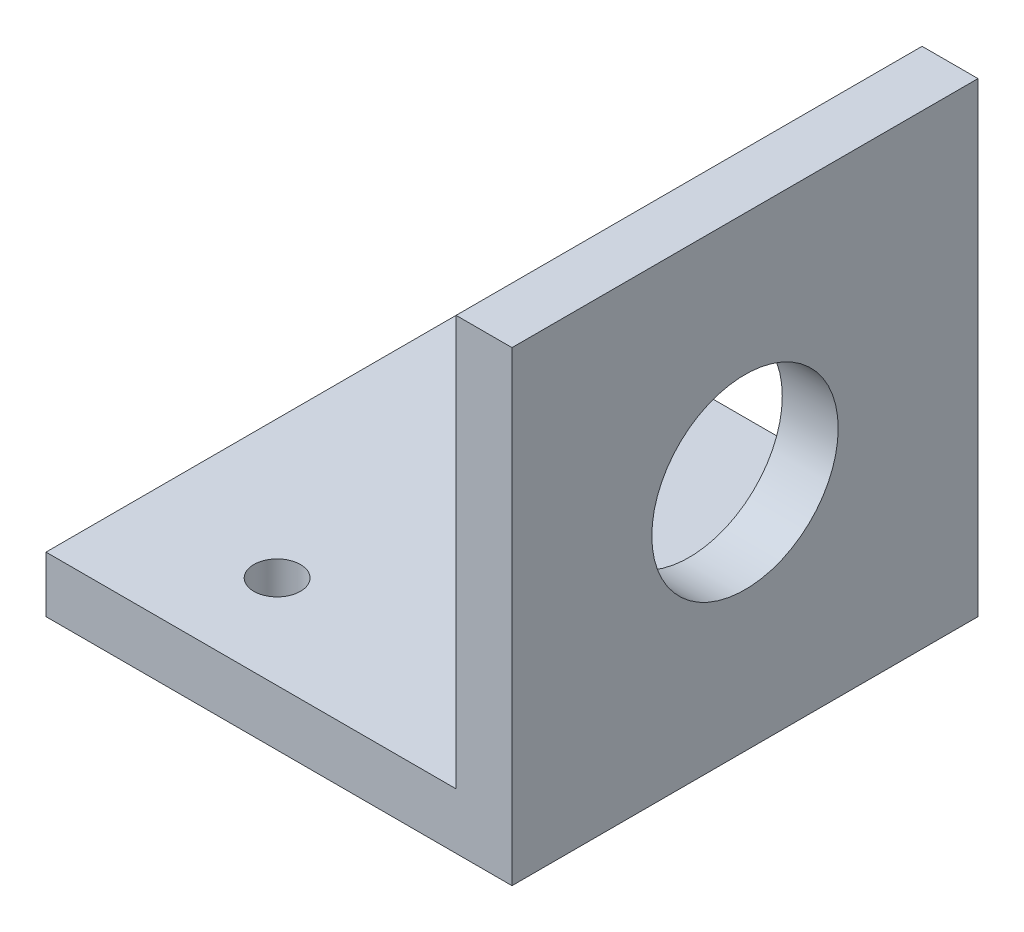
from build123d import *

# Parameters (mm, degrees)
SKETCH_1_W          = 50
SKETCH_1_H          = 50
EXTRUDE_1_DEPTH     = 6
SKETCH_2_W          = 6
SKETCH_2_H          = 50
EXTRUDE_2_DEPTH     = 44
SKETCH_3_R          = 10
CUT_EXTRUDE_1_DEPTH = 44
SKETCH_4_R          = 2.5
CUT_EXTRUDE_2_DEPTH = 44


with BuildPart() as part:
    # ｽｹｯﾁ1 → ﾎﾞｽ - 押し出し1 (new body)
    with BuildSketch(Plane(origin=(0, 0, 0), x_dir=(1, 0, 0), z_dir=(0, 1, 0))):
        Rectangle(SKETCH_1_W, SKETCH_1_H)
    extrude(amount=EXTRUDE_1_DEPTH)

    # ｽｹｯﾁ2 → ﾎﾞｽ - 押し出し2 (add)
    with BuildSketch(Plane(origin=(0, 6, 0), x_dir=(1, 0, 0), z_dir=(0, 1, 0))):
        with Locations((22, 0)):
            Rectangle(SKETCH_2_W, SKETCH_2_H)
    extrude(amount=EXTRUDE_2_DEPTH)

    # ｽｹｯﾁ3 → ｶｯﾄ - 押し出し1 (cut)
    with BuildSketch(Plane(origin=(25, 0, 0), x_dir=(0, 0, -1), z_dir=(1, 0, 0))):
        with Locations((0, 25)):
            Circle(SKETCH_3_R)
    extrude(amount=-CUT_EXTRUDE_1_DEPTH, mode=Mode.SUBTRACT)

    # ｽｹｯﾁ4 → ｶｯﾄ - 押し出し2 (cut)
    with BuildSketch(Plane.XZ):
        with Locations((-10.2, -15)):
            Circle(SKETCH_4_R)
        with Locations((-10.2, 15)):
            Circle(SKETCH_4_R)
    extrude(amount=-CUT_EXTRUDE_2_DEPTH, mode=Mode.SUBTRACT)


solid = part.part
